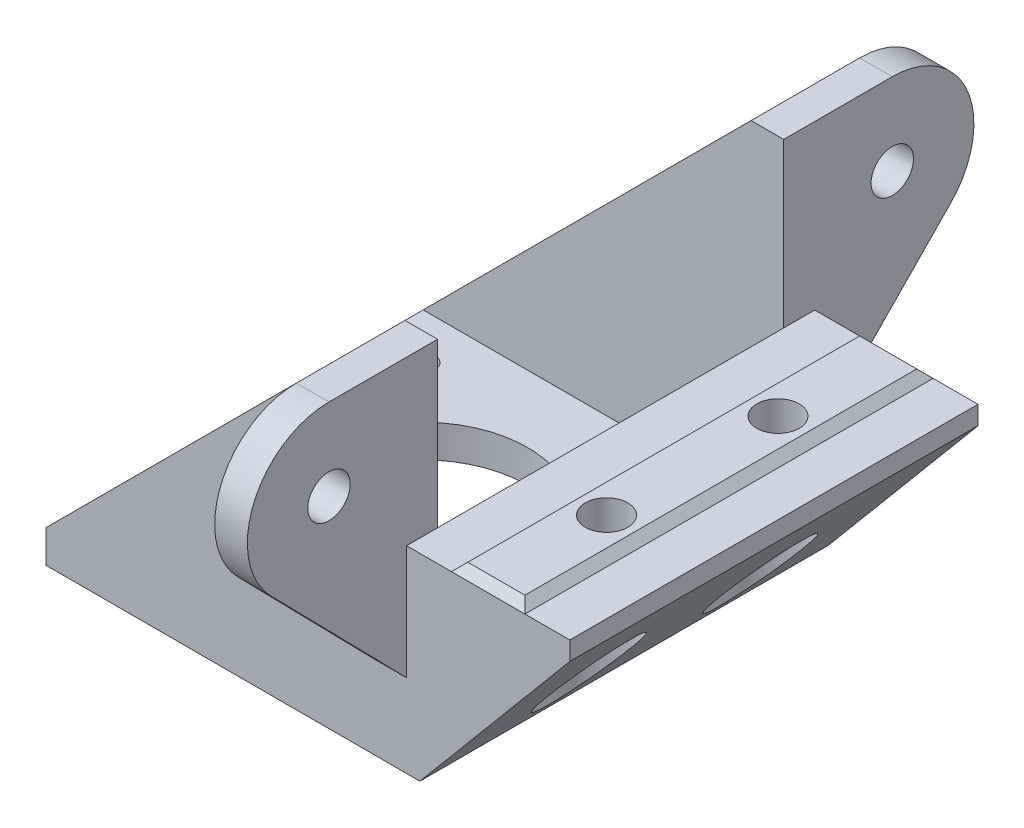
from build123d import *

# Parameters (mm, degrees)
BOSS_EXTRUDE1_DEPTH = 3.8
SKETCH2_W           = 45.8
SKETCH2_H           = 50
BOSS_EXTRUDE2_DEPTH = 4
BOSS_EXTRUDE3_DEPTH = 46.2
BOSS_EXTRUDE4_DEPTH = 3.8
BOSS_EXTRUDE5_REACH = 52
SKETCH6_W           = 9
SKETCH6_H           = 50
BOSS_EXTRUDE6_DEPTH = 1
BOSS_EXTRUDE6_TAPER = 45
SKETCH7_R           = 2.6
BOSS_EXTRUDE7_DEPTH = 4
CUT_EXTRUDE1_REACH  = 6
SKETCH8_R           = 13
SKETCH8_R_2         = 1.6
SKETCH9_R           = 2.6
CUT_EXTRUDE2_DEPTH  = 4.8
SKETCH10_R          = 5
CUT_EXTRUDE3_DEPTH  = 20


with BuildPart() as part:
    # Sketch1 → Boss-Extrude1 (new body)
    with BuildSketch(Plane.XY):
        Polygon((0, 0), (45.8, 0), (64.164, 21.885362974), (64.164, 24.164), (44.164, 24.164), (44.164, 44.164), (40.164, 44.164), (0, 4), align=None)
    extrude(amount=-BOSS_EXTRUDE1_DEPTH)

    # Sketch2 → Boss-Extrude2 (add)
    with BuildSketch(Plane.XZ):
        with Locations((22.9, -25)):
            Rectangle(SKETCH2_W, SKETCH2_H)
    extrude(amount=-BOSS_EXTRUDE2_DEPTH)

    # Sketch3 → Boss-Extrude3 (add, through all)
    with BuildSketch(Plane(origin=(0, 0, -3.8), x_dir=(-1, 0, 0), z_dir=(0, 0, -1))):
        Polygon((-45.8, 0), (-45.8, 4), (-49.156398525, 4), align=None)
    extrude(amount=BOSS_EXTRUDE3_DEPTH)

    # Sketch4 → Boss-Extrude4 (add)
    with BuildSketch(Plane(origin=(0, 0, -50), x_dir=(-1, 0, 0), z_dir=(0, 0, -1))):
        Polygon((-44.164, 24.164), (-44.164, 44.164), (-40.164, 44.164), (0, 4), (0, 0), (-45.8, 0), (-64.164, 21.885362974), (-64.164, 24.164), align=None)
    extrude(amount=-BOSS_EXTRUDE4_DEPTH)

    # Sketch5 → Boss-Extrude5 (add, up to next)
    with BuildSketch(Plane.XY, mode=Mode.PRIVATE) as boss_extrude5_sk1:
        Polygon((44.164, 24.164), (44.164, 0), (45.8, 0), (64.164, 21.885362974), (64.164, 24.164), align=None)
    boss_extrude5_tool1 = extrude(boss_extrude5_sk1.sketch, amount=-BOSS_EXTRUDE5_REACH, mode=Mode.PRIVATE) - part.part
    add(boss_extrude5_tool1.solids().sort_by_distance((51.403304, 15.489129, 0))[0])

    # Sketch6 → Boss-Extrude6 (add)
    with BuildSketch(Plane(origin=(0, 24.164, 0), x_dir=(1, 0, 0), z_dir=(0, 1, 0))):
        with Locations((54.164, 25)):
            Rectangle(SKETCH6_W, SKETCH6_H)
    extrude(amount=BOSS_EXTRUDE6_DEPTH, taper=BOSS_EXTRUDE6_TAPER)

    # Sketch7 → Boss-Extrude7 (add)
    with BuildSketch(Plane(origin=(44.164, 0, 0), x_dir=(0, 0, -1), z_dir=(1, 0, 0))):
        with BuildLine():
            Line((0, 24.164), (0, 10.164))
            Line((0, 10.164), (-16.646029173, 27.168696786))
            ThreePointArc((-16.646029173, 27.168696786), (-18.718270774, 38.040013923), (-9.5, 44.164))
            Line((-9.5, 44.164), (3.8, 44.164))
            Line((3.8, 44.164), (3.8, 24.164))
            Line((3.8, 24.164), (0, 24.164))
        make_face()
        with Locations((-9.5, 34.164)):
            Circle(SKETCH7_R, mode=Mode.SUBTRACT)
        with BuildLine():
            Line((46.2, 44.164), (46.2, 24.164))
            Line((46.2, 24.164), (50, 24.164))
            Line((50, 24.164), (50, 10.164))
            Line((50, 10.164), (66.646029173, 27.168696786))
            ThreePointArc((66.646029173, 27.168696786), (68.718270774, 38.040013923), (59.5, 44.164))
            Line((59.5, 44.164), (46.2, 44.164))
        make_face()
        with Locations((59.5, 34.164)):
            Circle(SKETCH7_R, mode=Mode.SUBTRACT)
    extrude(amount=-BOSS_EXTRUDE7_DEPTH)

    # Sketch8 → Cut-Extrude1 (cut, up to next)
    with BuildSketch(Plane(origin=(0, 4, 0), x_dir=(1, 0, 0), z_dir=(0, 1, 0)), mode=Mode.PRIVATE) as cut_extrude1_sk1:
        with Locations((21, 25)):
            Circle(SKETCH8_R)
    cut_extrude1_tool1 = extrude(cut_extrude1_sk1.sketch, amount=-CUT_EXTRUDE1_REACH, mode=Mode.PRIVATE) & part.part
    add(cut_extrude1_tool1.solids().sort_by_distance((21, 4, -25))[0], mode=Mode.SUBTRACT)
    # Sketch8 → Cut-Extrude1 (cut, up to next)
    with BuildSketch(Plane(origin=(0, 4, 0), x_dir=(1, 0, 0), z_dir=(0, 1, 0)), mode=Mode.PRIVATE) as cut_extrude1_sk2:
        with Locations((5.5, 40.5)):
            Circle(SKETCH8_R_2)
    cut_extrude1_tool2 = extrude(cut_extrude1_sk2.sketch, amount=-CUT_EXTRUDE1_REACH, mode=Mode.PRIVATE) & part.part
    add(cut_extrude1_tool2.solids().sort_by_distance((5.5, 4, -40.5))[0], mode=Mode.SUBTRACT)
    # Sketch8 → Cut-Extrude1 (cut, up to next)
    with BuildSketch(Plane(origin=(0, 4, 0), x_dir=(1, 0, 0), z_dir=(0, 1, 0)), mode=Mode.PRIVATE) as cut_extrude1_sk3:
        with Locations((38.664, 40.5)):
            Circle(SKETCH8_R_2)
    cut_extrude1_tool3 = extrude(cut_extrude1_sk3.sketch, amount=-CUT_EXTRUDE1_REACH, mode=Mode.PRIVATE) & part.part
    add(cut_extrude1_tool3.solids().sort_by_distance((38.664, 4, -40.5))[0], mode=Mode.SUBTRACT)
    # Sketch8 → Cut-Extrude1 (cut, up to next)
    with BuildSketch(Plane(origin=(0, 4, 0), x_dir=(1, 0, 0), z_dir=(0, 1, 0)), mode=Mode.PRIVATE) as cut_extrude1_sk4:
        with Locations((38.664, 7.336)):
            Circle(SKETCH8_R_2)
    cut_extrude1_tool4 = extrude(cut_extrude1_sk4.sketch, amount=-CUT_EXTRUDE1_REACH, mode=Mode.PRIVATE) & part.part
    add(cut_extrude1_tool4.solids().sort_by_distance((38.664, 4, -7.336))[0], mode=Mode.SUBTRACT)
    # Sketch8 → Cut-Extrude1 (cut, up to next)
    with BuildSketch(Plane(origin=(0, 4, 0), x_dir=(1, 0, 0), z_dir=(0, 1, 0)), mode=Mode.PRIVATE) as cut_extrude1_sk5:
        with Locations((5.5, 7.336)):
            Circle(SKETCH8_R_2)
    cut_extrude1_tool5 = extrude(cut_extrude1_sk5.sketch, amount=-CUT_EXTRUDE1_REACH, mode=Mode.PRIVATE) & part.part
    add(cut_extrude1_tool5.solids().sort_by_distance((5.5, 4, -7.336))[0], mode=Mode.SUBTRACT)

    # Sketch9 → Cut-Extrude2 (cut)
    with BuildSketch(Plane(origin=(0, 25.164, 0), x_dir=(1, 0, 0), z_dir=(0, 1, 0))):
        with Locations((54.164, 14.5)):
            Circle(SKETCH9_R)
        with Locations((54.164, 35.5)):
            Circle(SKETCH9_R)
    extrude(amount=-CUT_EXTRUDE2_DEPTH, mode=Mode.SUBTRACT)

    # Sketch10 → Cut-Extrude3 (cut)
    with BuildSketch(Plane.XZ):
        with Locations((52, -14.5)):
            Circle(SKETCH10_R)
        with Locations((52, -35.5)):
            Circle(SKETCH10_R)
    extrude(amount=-CUT_EXTRUDE3_DEPTH, mode=Mode.SUBTRACT)


solid = part.part
